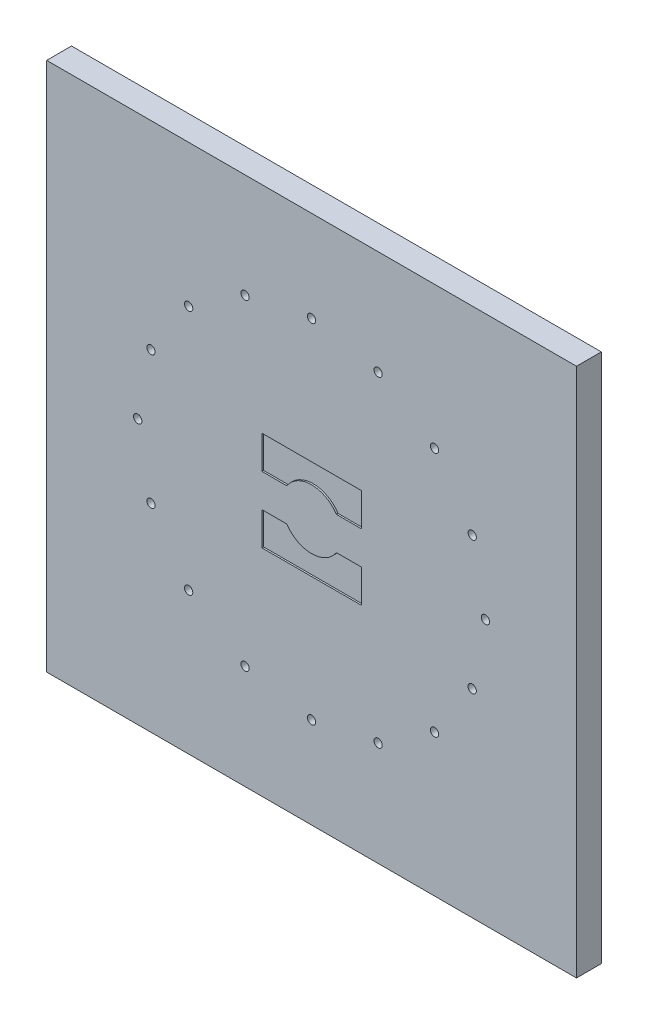
from build123d import *

# Parameters (mm, degrees)
ESQUISSE1_W             = 32
ESQUISSE1_H             = 32
BOSS_EXTRU_1_DEPTH      = 1.5
ESQUISSE2_R             = 10.05
ESQUISSE2_R_2           = 9.95
ENL_V_MAT_EXTRU_1_DEPTH = 0.2
ESQUISSE3_R             = 0.25
ENL_V_MAT_EXTRU_2_DEPTH = 2.5
ESQUISSE4_W             = 31
ESQUISSE4_H             = 31
ENL_V_MAT_EXTRU_3_DEPTH = 0.1
ENL_V_MAT_EXTRU_4_DEPTH = 0.1


with BuildPart() as part:
    # Esquisse1 → Boss.-Extru.1 (new body)
    with BuildSketch(Plane.XY):
        Rectangle(ESQUISSE1_W, ESQUISSE1_H)
    extrude(amount=BOSS_EXTRU_1_DEPTH)

    # Esquisse2 → Enlèv. mat.-Extru.1 (cut)
    with BuildSketch(Plane(origin=(0, 0, 0), x_dir=(-1, 0, 0), z_dir=(0, 0, -1))):
        Circle(ESQUISSE2_R)
        Circle(ESQUISSE2_R_2, mode=Mode.SUBTRACT)
    extrude(amount=-ENL_V_MAT_EXTRU_1_DEPTH, mode=Mode.SUBTRACT)

    # Esquisse3 → Enlèv. mat.-Extru.2 (cut, through all)
    with BuildSketch(Plane(origin=(0, 0, 0), x_dir=(-1, 0, 0), z_dir=(0, 0, -1))):
        with Locations((0, 10.5)):
            Circle(ESQUISSE3_R)
        with Locations((4.01817604, 9.700735091)):
            Circle(ESQUISSE3_R)
        with Locations((7.424621202, 7.424621202)):
            Circle(ESQUISSE3_R)
        with Locations((9.700735091, 4.01817604)):
            Circle(ESQUISSE3_R)
        with Locations((10.5, 0)):
            Circle(ESQUISSE3_R)
        with Locations((9.700735091, -4.01817604)):
            Circle(ESQUISSE3_R)
        with Locations((7.424621202, -7.424621202)):
            Circle(ESQUISSE3_R)
        with Locations((4.01817604, -9.700735091)):
            Circle(ESQUISSE3_R)
        with Locations((0, -10.5)):
            Circle(ESQUISSE3_R)
        with Locations((-4.01817604, -9.700735091)):
            Circle(ESQUISSE3_R)
        with Locations((-7.424621202, -7.424621202)):
            Circle(ESQUISSE3_R)
        with Locations((-9.700735091, -4.01817604)):
            Circle(ESQUISSE3_R)
        with Locations((-10.5, 0)):
            Circle(ESQUISSE3_R)
        with Locations((-9.700735091, 4.01817604)):
            Circle(ESQUISSE3_R)
        with Locations((-7.424621202, 7.424621202)):
            Circle(ESQUISSE3_R)
        with Locations((-4.01817604, 9.700735091)):
            Circle(ESQUISSE3_R)
    extrude(amount=-ENL_V_MAT_EXTRU_2_DEPTH, mode=Mode.SUBTRACT)

    # Esquisse4 → Enlèv. mat.-Extru.3 (cut)
    with BuildSketch(Plane(origin=(0, 0, 0), x_dir=(-1, 0, 0), z_dir=(0, 0, -1))):
        Rectangle(ESQUISSE4_W, ESQUISSE4_H)
    extrude(amount=-ENL_V_MAT_EXTRU_3_DEPTH, mode=Mode.SUBTRACT)

    # Esquisse5 → Enlèv. mat.-Extru.4 (cut)
    with BuildSketch(Plane.XY.offset(1.5)):
        with BuildLine():
            Line((-3, 3), (3, 3))
            Line((3, 3), (3, 1))
            Line((3, 1), (1.5, 1))
            ThreePointArc((1.5, 1), (0, 1.802775638), (-1.5, 1))
            Line((-1.5, 1), (-3, 1))
            Line((-3, 1), (-3, 3))
        make_face()
        with BuildLine():
            Line((-3, -3), (-3, -1))
            Line((-3, -1), (-1.5, -1))
            ThreePointArc((-1.5, -1), (0, -1.802775638), (1.5, -1))
            Line((1.5, -1), (3, -1))
            Line((3, -1), (3, -3))
            Line((3, -3), (-3, -3))
        make_face()
    extrude(amount=-ENL_V_MAT_EXTRU_4_DEPTH, mode=Mode.SUBTRACT)


solid = part.part
